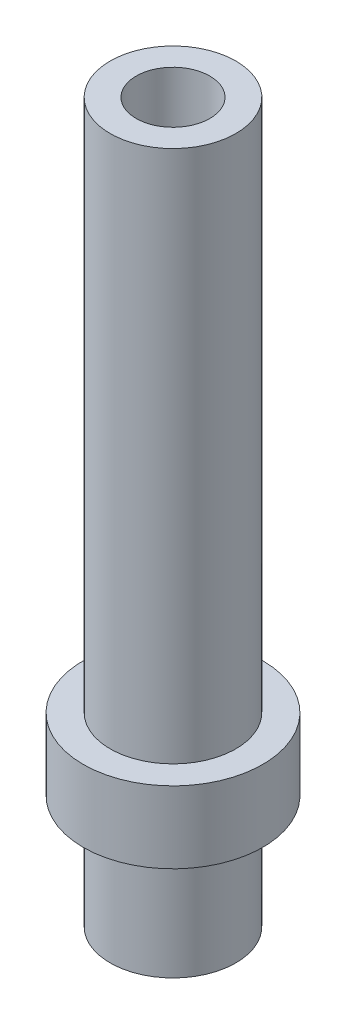
from build123d import *


with BuildPart() as part:
    # Sketch1 → Revolve1 (revolve)
    with BuildSketch(Plane(origin=(0, 0, 0), x_dir=(0, 0, -1), z_dir=(1, 0, 0))):
        Polygon((10.25, 0), (10.25, 200), (17.5, 200), (17.5, 51.623323598), (25, 51.623323598), (25, 31.623323598), (17.5, 31.623323598), (17.5, 0), align=None)
    revolve(axis=Axis((0, 0, 0), (0, 1, 0)))


solid = part.part
